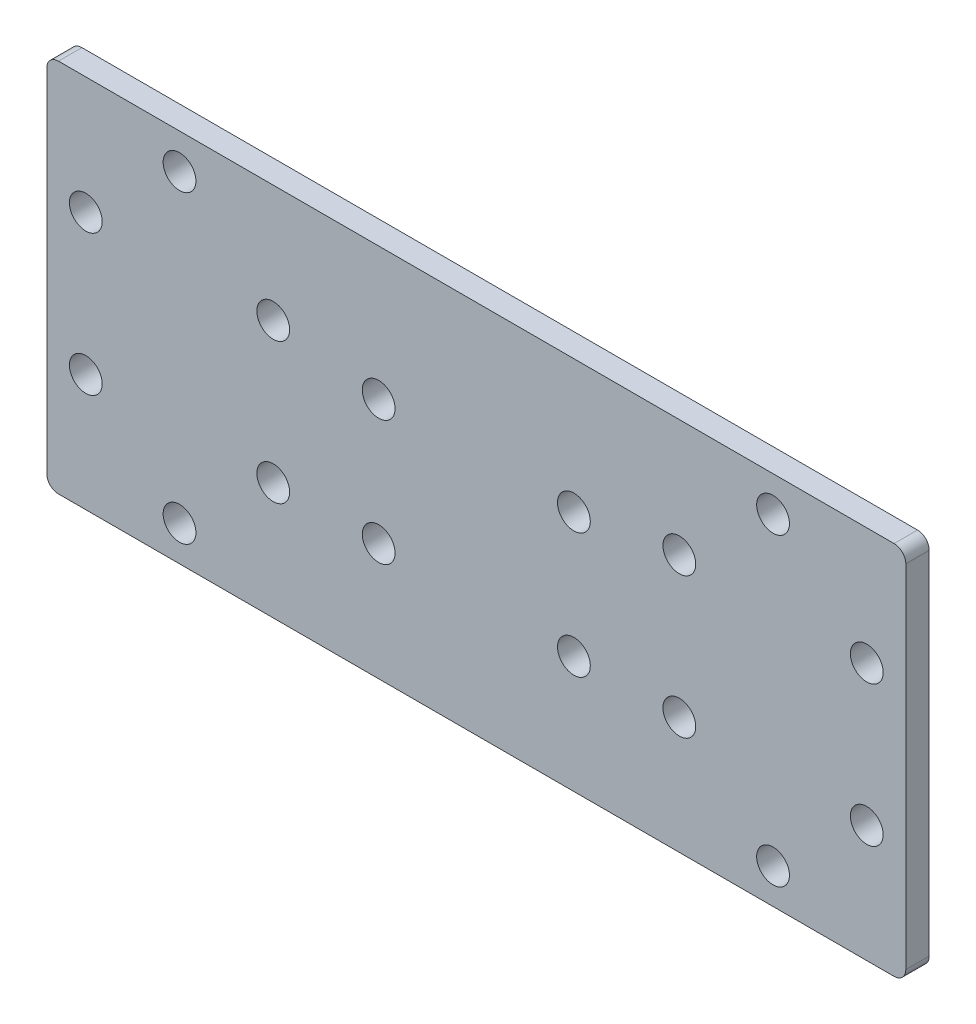
from build123d import *

# Parameters (mm, degrees)
SKETCH1_W           = 110
SKETCH1_H           = 48
SKETCH1_R           = 2.1
BOSS_EXTRUDE1_DEPTH = 1.5
FILLET1_R           = 1.5


with BuildPart() as part:
    # Sketch1 → Boss-Extrude1 (new body, symmetric)
    with BuildSketch(Plane.XY):
        Rectangle(SKETCH1_W, SKETCH1_H)
        with Locations((50, 9)):
            Circle(SKETCH1_R, mode=Mode.SUBTRACT)
        with Locations((26, 9)):
            Circle(SKETCH1_R, mode=Mode.SUBTRACT)
        with Locations((50, -9)):
            Circle(SKETCH1_R, mode=Mode.SUBTRACT)
        with Locations((26, -9)):
            Circle(SKETCH1_R, mode=Mode.SUBTRACT)
        with Locations((-50, 9)):
            Circle(SKETCH1_R, mode=Mode.SUBTRACT)
        with Locations((-26, 9)):
            Circle(SKETCH1_R, mode=Mode.SUBTRACT)
        with Locations((-50, -9)):
            Circle(SKETCH1_R, mode=Mode.SUBTRACT)
        with Locations((-26, -9)):
            Circle(SKETCH1_R, mode=Mode.SUBTRACT)
        with Locations((-38, 19.5)):
            Circle(SKETCH1_R, mode=Mode.SUBTRACT)
        with Locations((-38, -19.5)):
            Circle(SKETCH1_R, mode=Mode.SUBTRACT)
        with Locations((38, 19.5)):
            Circle(SKETCH1_R, mode=Mode.SUBTRACT)
        with Locations((38, -19.5)):
            Circle(SKETCH1_R, mode=Mode.SUBTRACT)
        with Locations((12.5, -9)):
            Circle(SKETCH1_R, mode=Mode.SUBTRACT)
        with Locations((-12.5, -9)):
            Circle(SKETCH1_R, mode=Mode.SUBTRACT)
        with Locations((-12.5, 7)):
            Circle(SKETCH1_R, mode=Mode.SUBTRACT)
        with Locations((12.5, 7)):
            Circle(SKETCH1_R, mode=Mode.SUBTRACT)
    extrude(amount=BOSS_EXTRUDE1_DEPTH, both=True)

    # Fillet1
    fillet1_edges = [part.edges().sort_by_distance(p)[0] for p in [
        (-55, 24, 0),
        (55, 24, 0),
        (55, -24, 0),
        (-55, -24, 0),
    ]]
    fillet(fillet1_edges, radius=FILLET1_R)


solid = part.part
